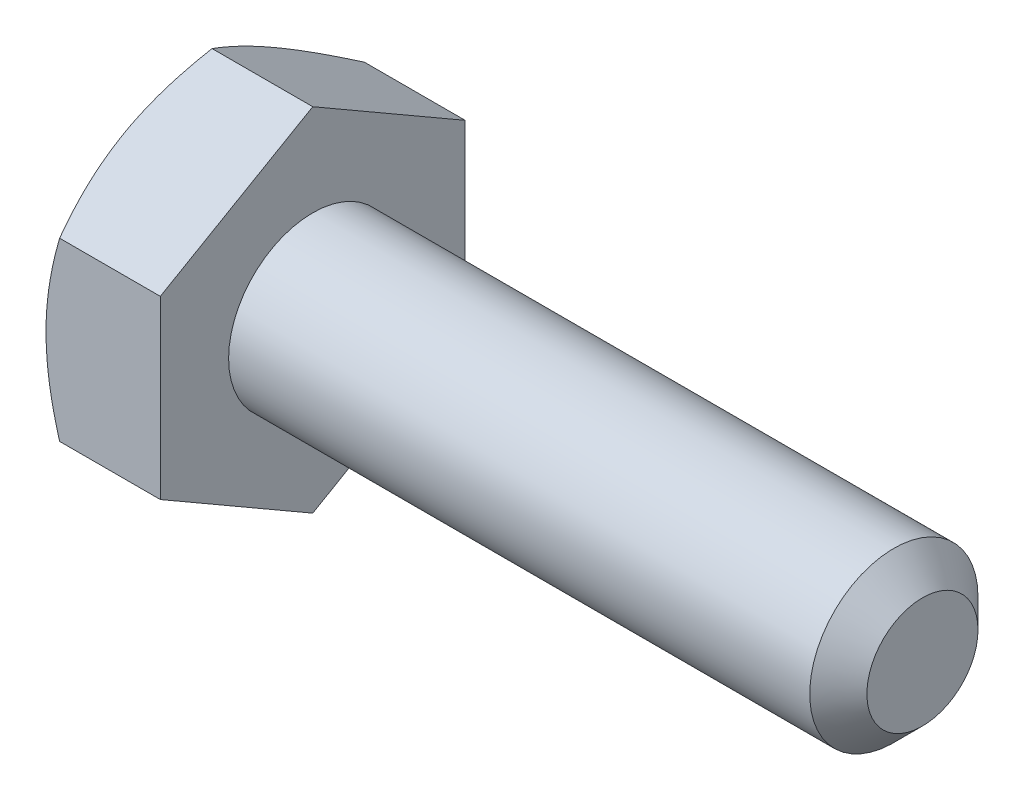
from build123d import *

# Parameters (mm, degrees)
SKETCH5_R           = 1.7526
BOSS_EXTRUDE3_DEPTH = 12.7
CHAMFER1_SIZE       = 0.5953125
BOSS_EXTRUDE4_DEPTH = 2.38125
SKETCH8_OUTSIDE_W   = 67.644
SKETCH8_OUTSIDE_H   = 68.626
SKETCH8_OUTSIDE_R   = 3.175
CUT_EXTRUDE3_DEPTH  = 16.08125
CUT_EXTRUDE3_TAPER  = 60
CUT_EXTRUDE4_DEPTH  = 0.254
CIRPATTERN1_COUNT   = 6


with BuildPart() as part:
    # Sketch5 → Boss-Extrude3 (new body)
    with BuildSketch(Plane(origin=(7.540625, 0, 0), x_dir=(0, 0, -1), z_dir=(1, 0, 0))):
        Circle(SKETCH5_R)
    extrude(amount=-BOSS_EXTRUDE3_DEPTH)

    # Chamfer1
    chamfer1_edges = [part.edges().sort_by_distance(p)[0] for p in [
        (7.540625, 0, 1.7526),
    ]]
    chamfer(chamfer1_edges, length=CHAMFER1_SIZE)

    # Sketch6 → Boss-Extrude4 (add)
    with BuildSketch(Plane.ZY.offset(5.159375)):
        Polygon((3.175, 1.833087105), (0, 3.666174209), (-3.175, 1.833087105), (-3.175, -1.833087105), (0, -3.666174209), (3.175, -1.833087105), align=None)
    extrude(amount=BOSS_EXTRUDE4_DEPTH)

    # Sketch8 outside → Cut-Extrude3 (cut, through all)
    with BuildSketch(Plane.ZY.offset(7.540625)):
        Rectangle(SKETCH8_OUTSIDE_W, SKETCH8_OUTSIDE_H)
        Circle(SKETCH8_OUTSIDE_R, mode=Mode.SUBTRACT)
    extrude(amount=-CUT_EXTRUDE3_DEPTH, taper=CUT_EXTRUDE3_TAPER, mode=Mode.SUBTRACT)

    # Sketch12 → Cut-Extrude4 (cut)
    with BuildSketch(Plane.ZY.offset(7.540625)):
        with BuildLine():
            Line((0.09525, 2.44475), (0.09525, 1.36525))
            ThreePointArc((0.09525, 1.36525), (0, 1.27), (-0.09525, 1.36525))
            Line((-0.09525, 1.36525), (-0.09525, 2.44475))
            ThreePointArc((-0.09525, 2.44475), (0, 2.54), (0.09525, 2.44475))
        make_face()
    cut_extrude4 = extrude(amount=-CUT_EXTRUDE4_DEPTH, mode=Mode.SUBTRACT)

    # CirPattern1: Cut-Extrude4 ×6 about axis
    cirpattern1_axis = Axis((0, 0, 0), (1, 0, 0))
    for i in range(1, CIRPATTERN1_COUNT):
        add(cut_extrude4.rotate(cirpattern1_axis, i * 360 / CIRPATTERN1_COUNT), mode=Mode.SUBTRACT)


solid = part.part
